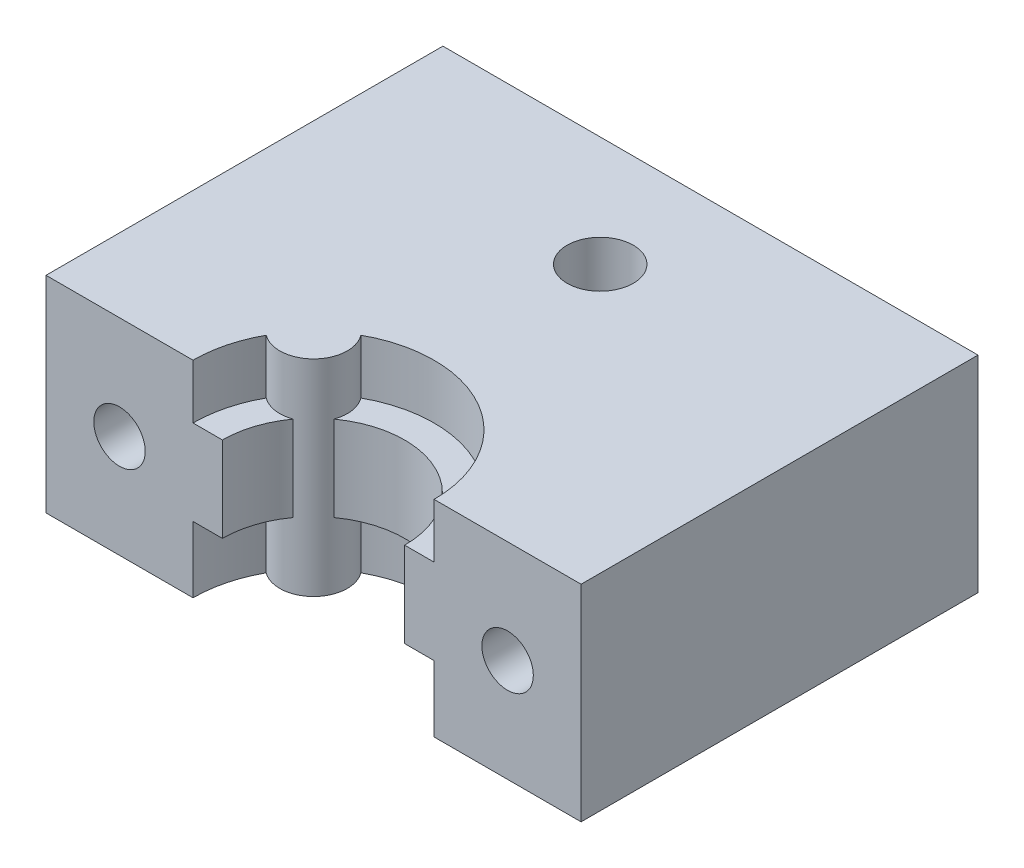
from build123d import *

# Parameters (mm, degrees)
SKETCH1_W                          = 36.4
SKETCH1_H                          = 14
BOSS_EXTRUDE1_DEPTH                = 27
CUT_EXTRUDE1_DEPTH                 = 14
BOSS_EXTRUDE2_START                = -3.7
BOSS_EXTRUDE2_DEPTH                = 5.8
SKETCH3_R                          = 1.75
CUT_EXTRUDE2_DEPTH                 = 27
SKETCH5_R                          = 3.25
CUT_EXTRUDE3_DEPTH                 = 5
SKETCH6_R                          = 2.25
HEAT_SET_INSERT_FOR_EXTRUDER_DEPTH = 7
SKETCH8_R                          = 2.25
CUT_EXTRUDE4_DEPTH                 = 4


with BuildPart() as part:
    # Sketch1 → Boss-Extrude1 (new body)
    with BuildSketch(Plane.XY):
        with Locations((18.2, 7)):
            Rectangle(SKETCH1_W, SKETCH1_H)
    extrude(amount=-BOSS_EXTRUDE1_DEPTH)

    # Sketch2 → Cut-Extrude1 (cut)
    with BuildSketch(Plane(origin=(0, 14, 0), x_dir=(1, 0, 0), z_dir=(0, 1, 0))):
        with BuildLine():
            ThreePointArc((11.019537046, 3.959918151), (10.258973737, 2.044529747), (10, 0))
            Line((10, 0), (26.4, 0))
            ThreePointArc((26.4, 0), (22.369452672, 7.060854369), (14.240081849, 7.180462954))
            ThreePointArc((14.240081849, 7.180462954), (14.028069991, 4.171930009), (11.019537046, 3.959918151))
        make_face()
    extrude(amount=-CUT_EXTRUDE1_DEPTH, mode=Mode.SUBTRACT)

    # Sketch4 → Boss-Extrude2 (add)
    with BuildSketch(Plane(origin=(0, 14, 0), x_dir=(1, 0, 0), z_dir=(0, 1, 0)).offset(BOSS_EXTRUDE2_START)):
        with BuildLine():
            Line((12, 0), (10, 0))
            ThreePointArc((10, 0), (18.2, 8.2), (26.4, 0))
            Line((26.4, 0), (24.4, 0))
            ThreePointArc((24.4, 0), (18.2, 6.2), (12, 0))
        make_face()
    extrude(amount=-BOSS_EXTRUDE2_DEPTH)

    # Sketch3 → Cut-Extrude2 (cut)
    with BuildSketch(Plane.XY):
        with Locations((5, 7)):
            Circle(SKETCH3_R)
        with Locations((31.4, 7)):
            Circle(SKETCH3_R)
    extrude(amount=-CUT_EXTRUDE2_DEPTH, mode=Mode.SUBTRACT)

    # Sketch5 → Cut-Extrude3 (cut)
    with BuildSketch(Plane(origin=(0, 0, -27), x_dir=(-1, 0, 0), z_dir=(0, 0, -1))):
        with Locations((-31.4, 7)):
            Circle(SKETCH5_R)
        with Locations((-5, 7)):
            Circle(SKETCH5_R)
    extrude(amount=-CUT_EXTRUDE3_DEPTH, mode=Mode.SUBTRACT)

    # Sketch6 → heat set insert for extruder (cut)
    with BuildSketch(Plane(origin=(0, 14, 0), x_dir=(1, 0, 0), z_dir=(0, 1, 0))):
        with Locations((18.2, 19.5)):
            Circle(SKETCH6_R)
    extrude(amount=-HEAT_SET_INSERT_FOR_EXTRUDER_DEPTH, mode=Mode.SUBTRACT)

    # Sketch8 → Cut-Extrude4 (cut)
    with BuildSketch(Plane(origin=(0, 0, -27), x_dir=(-1, 0, 0), z_dir=(0, 0, -1))):
        with Locations((-24, 8)):
            Circle(SKETCH8_R)
    extrude(amount=-CUT_EXTRUDE4_DEPTH, mode=Mode.SUBTRACT)


solid = part.part
